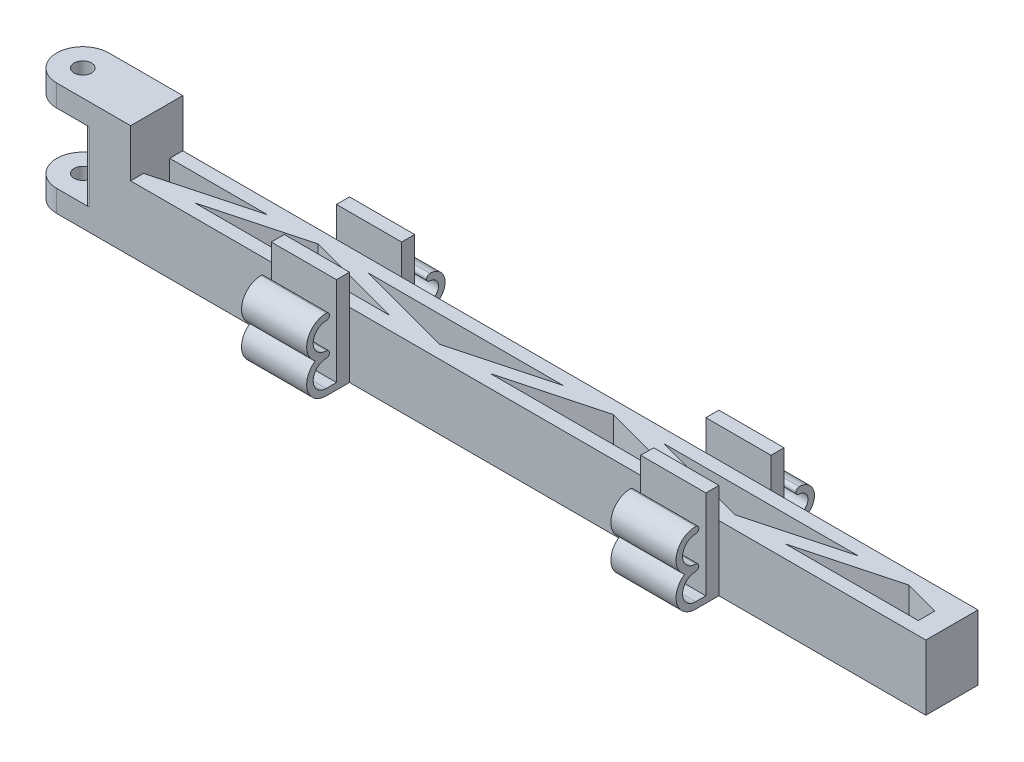
from build123d import *

# Parameters (mm, degrees)
SKETCH1_R            = 2
BOSS_EXTRUDE1_DEPTH  = 15
SKETCH2_R            = 2
BOSS_EXTRUDE2_DEPTH  = 5
SKETCH3_R            = 8
CUT_EXTRUDE1_DEPTH   = 15
BOSS_EXTRUDE3_DEPTH  = 15
SKETCH5_R            = 2
BOSS_EXTRUDE4_DEPTH  = 5
FILLET4_R            = 1
SKETCH11_W           = 15
SKETCH11_H           = 3
BOSS_EXTRUDE6_DEPTH  = 22
CUT_EXTRUDE4_DEPTH   = 8
BOSS_EXTRUDE7_DEPTH  = 1
SKETCH14_R           = 2
BOSS_EXTRUDE8_DEPTH  = 5
BOSS_EXTRUDE9_DEPTH  = 15
BOSS_EXTRUDE10_DEPTH = 15
BOSS_EXTRUDE11_DEPTH = 15
BOSS_EXTRUDE12_DEPTH = 15


with BuildPart() as part:
    # Sketch1 → Boss-Extrude1 (new body)
    with BuildSketch(Plane(origin=(0, 0, 0), x_dir=(1, 0, 0), z_dir=(0, 1, 0))):
        with BuildLine():
            Line((0, -6), (200, -6))
            Line((200, -6), (200, 6))
            Line((200, 6), (0, 6))
            ThreePointArc((0, 6), (-3, 5.196152423), (-5.196152423, 3))
            ThreePointArc((-5.196152423, 3), (-5.197498369, 2.997667544), (-5.198843268, 2.995334485))
            ThreePointArc((-5.198843268, 2.995334485), (-5.19480543, -3.002331851), (0, -6))
        make_face()
        Circle(SKETCH1_R, mode=Mode.SUBTRACT)
        with BuildLine():
            Line((39.568354484, 3), (17.176049639, -3))
            Line((17.176049639, -3), (5.999997583, -0.005385877))
            ThreePointArc((5.999997583, -0.005385877), (5.999999396, -0.002692939), (6, 0))
            ThreePointArc((6, 0), (5.795554958, 1.552914271), (5.196152423, 3))
            Line((5.196152423, 3), (39.568354484, 3))
        make_face(mode=Mode.SUBTRACT)
        Polygon((73.551769245, -3), (28.767159554, -3), (51.1594644, 3), align=None, mode=Mode.SUBTRACT)
        Polygon((85.142879161, -3), (62.750574315, 3), (107.535184006, 3), align=None, mode=Mode.SUBTRACT)
        Polygon((141.518598767, -3), (96.733989076, -3), (119.126293922, 3), align=None, mode=Mode.SUBTRACT)
        Polygon((153.109708683, -3), (130.717403837, 3), (175.502013528, 3), align=None, mode=Mode.SUBTRACT)
        Polygon((195.25744983, 0.812375338), (195.25744983, -3), (164.700818598, -3), (187.093123443, 3), align=None, mode=Mode.SUBTRACT)
    extrude(amount=BOSS_EXTRUDE1_DEPTH)

    # Sketch2 → Boss-Extrude2 (add)
    with BuildSketch(Plane(origin=(0, 15, 0), x_dir=(1, 0, 0), z_dir=(0, 1, 0))):
        with BuildLine():
            Line((0, 6), (17, 6))
            Line((17, 6), (17, -6))
            Line((17, -6), (0, -6))
            ThreePointArc((0, -6), (-6, 0), (0, 6))
        make_face()
        Circle(SKETCH2_R, mode=Mode.SUBTRACT)
    extrude(amount=BOSS_EXTRUDE2_DEPTH)

    # Sketch3 → Cut-Extrude1 (cut)
    with BuildSketch(Plane.XZ):
        Circle(SKETCH3_R)
    extrude(amount=-CUT_EXTRUDE1_DEPTH, mode=Mode.SUBTRACT)

    # Sketch4 → Boss-Extrude3 (add)
    with BuildSketch(Plane.XZ.offset(-15)):
        with BuildLine():
            Line((7.416198487, -3), (17, -3))
            Line((17, -3), (17, 2.952827641))
            Line((17, 2.952827641), (7.981992906, 0.536459923))
            ThreePointArc((7.981992906, 0.536459923), (7.899538704, -1.2638387), (7.416198487, -3))
        make_face()
    extrude(amount=BOSS_EXTRUDE3_DEPTH)

    # Sketch5 → Boss-Extrude4 (add)
    with BuildSketch(Plane.XZ):
        with BuildLine():
            Line((17, -6), (17, 6))
            Line((17, 6), (0, 6))
            ThreePointArc((0, 6), (-6, 0), (0, -6))
            Line((0, -6), (17, -6))
        make_face()
        Circle(SKETCH5_R, mode=Mode.SUBTRACT)
    extrude(amount=-BOSS_EXTRUDE4_DEPTH)

    # Fillet4
    fillet4_edges = [part.edges().sort_by_distance(p)[0] for p in [
        (5.291502622, 10, -6),
        (5.291502622, 10, 6),
    ]]
    fillet(fillet4_edges, radius=FILLET4_R)

    # Sketch11 → Boss-Extrude6 (add)
    with BuildSketch(Plane.XZ):
        with Locations((59.870503333, 7.5)):
            Rectangle(SKETCH11_W, SKETCH11_H)
        with Locations((59.870503333, -7.5)):
            Rectangle(SKETCH11_W, SKETCH11_H)
        with Locations((144.870503333, 7.5)):
            Rectangle(SKETCH11_W, SKETCH11_H)
        with Locations((144.870503333, -7.5)):
            Rectangle(SKETCH11_W, SKETCH11_H)
    extrude(amount=-BOSS_EXTRUDE6_DEPTH)

    # Sketch12 → Cut-Extrude4 (cut, through all)
    with BuildSketch(Plane.XZ.offset(-15)):
        with BuildLine():
            Line((0, -6), (7.483314774, -6))
            ThreePointArc((7.483314774, -6), (6.60139767, -5.471404521), (6.651835354, -4.444444444))
            ThreePointArc((6.651835354, -4.444444444), (8, 0), (6.651835354, 4.444444444))
            ThreePointArc((6.651835354, 4.444444444), (6.60139767, 5.471404521), (7.483314774, 6))
            Line((7.483314774, 6), (0, 6))
            ThreePointArc((0, 6), (-6, 0), (0, -6))
        make_face()
    extrude(amount=-CUT_EXTRUDE4_DEPTH, mode=Mode.SUBTRACT)

    # Sketch13 → Boss-Extrude7 (add)
    with BuildSketch(Plane(origin=(0, 20, 0), x_dir=(1, 0, 0), z_dir=(0, 1, 0))):
        with BuildLine():
            Line((7.483314774, -6), (17, -6))
            Line((17, -6), (17, 6))
            Line((17, 6), (7.483314774, 6))
            ThreePointArc((7.483314774, 6), (6.60139767, 5.471404521), (6.651835354, 4.444444444))
            ThreePointArc((6.651835354, 4.444444444), (8, 0), (6.651835354, -4.444444444))
            ThreePointArc((6.651835354, -4.444444444), (6.60139767, -5.471404521), (7.483314774, -6))
        make_face()
    extrude(amount=BOSS_EXTRUDE7_DEPTH)

    # Sketch14 → Boss-Extrude8 (add)
    with BuildSketch(Plane(origin=(0, 21, 0), x_dir=(1, 0, 0), z_dir=(0, 1, 0))):
        with BuildLine():
            Line((0, -6), (7.483314774, -6))
            Line((7.483314774, -6), (17, -6))
            Line((17, -6), (17, 6))
            Line((17, 6), (7.483314774, 6))
            Line((7.483314774, 6), (0, 6))
            ThreePointArc((0, 6), (-6, 0), (0, -6))
        make_face()
        Circle(SKETCH14_R, mode=Mode.SUBTRACT)
    extrude(amount=BOSS_EXTRUDE8_DEPTH)

    # Sketch17 → Boss-Extrude9 (add)
    with BuildSketch(Plane.ZY.offset(-52.370503333)):
        with BuildLine():
            Line((-12.5, 1.5), (-9, 1.5))
            Line((-9, 1.5), (-9, 0))
            Line((-9, 0), (-12.5, 0))
            ThreePointArc((-12.5, 0), (-15.807189139, 2.354356076), (-14.665063509, 6.25))
            ThreePointArc((-14.665063509, 6.25), (-15.807189139, 10.145643924), (-12.5, 12.5))
            ThreePointArc((-12.5, 12.5), (-11.75, 11.75), (-12.5, 11))
            ThreePointArc((-12.5, 11), (-14.5, 9), (-12.5, 7))
            ThreePointArc((-12.5, 7), (-11.75, 6.25), (-12.5, 5.5))
            ThreePointArc((-12.5, 5.5), (-14.5, 3.5), (-12.5, 1.5))
        make_face()
    extrude(amount=-BOSS_EXTRUDE9_DEPTH)

    # Sketch18 → Boss-Extrude10 (add)
    with BuildSketch(Plane(origin=(152.370503333, 0, 0), x_dir=(0, 0, -1), z_dir=(1, 0, 0))):
        with BuildLine():
            Line((6, 0), (12.5, 0))
            ThreePointArc((12.5, 0), (15.807189139, 2.354356076), (14.665063509, 6.25))
            ThreePointArc((14.665063509, 6.25), (15.807189139, 10.145643924), (12.5, 12.5))
            ThreePointArc((12.5, 12.5), (11.75, 11.75), (12.5, 11))
            ThreePointArc((12.5, 11), (14.5, 9), (12.5, 7))
            ThreePointArc((12.5, 7), (11.75, 6.25), (12.5, 5.5))
            ThreePointArc((12.5, 5.5), (14.5, 3.5), (12.5, 1.5))
            Line((12.5, 1.5), (9, 1.5))
            Line((9, 1.5), (9, 22))
            Line((9, 22), (6, 22))
            Line((6, 22), (6, 15))
            Line((6, 15), (6, 0))
        make_face()
    extrude(amount=-BOSS_EXTRUDE10_DEPTH)

    # Sketch20 → Boss-Extrude11 (add)
    with BuildSketch(Plane(origin=(152.370503333, 0, 0), x_dir=(0, 0, -1), z_dir=(1, 0, 0))):
        with BuildLine():
            Line((-11.364782306, 0), (-9, 0))
            Line((-9, 0), (-9, 1.5))
            Line((-9, 1.5), (-11.364782306, 1.5))
            add(Edge.make_bspline(
                [(-11.364782306, 7.5), (-14.358451493, 7.5), (-14.358451493, 4.5), (-14.358451493, 1.5), (-11.364782306, 1.5)],
                knots=[0, 0, 0, 1.570796327, 1.570796327, 3.141592654, 3.141592654, 3.141592654], degree=2, weights=[1, 0.707106781, 1, 0.707106781, 1]))
            add(Edge.make_bspline(
                [(-11.364782306, 7.5), (-10.616365009, 7.5), (-10.616365009, 8.25), (-10.616365009, 9), (-11.364782306, 9)],
                knots=[3.141592654, 3.141592654, 3.141592654, 4.71238898, 4.71238898, 6.283185307, 6.283185307, 6.283185307], degree=2, weights=[1, 0.707106781, 1, 0.707106781, 1]))
            add(Edge.make_bspline(
                [(-11.364782306, 15), (-14.358451493, 15), (-14.358451493, 12), (-14.358451493, 9), (-11.364782306, 9)],
                knots=[0, 0, 0, 1.570796327, 1.570796327, 3.141592654, 3.141592654, 3.141592654], degree=2, weights=[1, 0.707106781, 1, 0.707106781, 1]))
            add(Edge.make_bspline(
                [(-11.364782306, 15), (-10.616365009, 15), (-10.616365009, 15.75), (-10.616365009, 16.5), (-11.364782306, 16.5)],
                knots=[3.141592654, 3.141592654, 3.141592654, 4.71238898, 4.71238898, 6.283185307, 6.283185307, 6.283185307], degree=2, weights=[1, 0.707106781, 1, 0.707106781, 1]))
            add(Edge.make_bspline(
                [(-11.364782306, 16.5), (-26.258098465, 16.5), (-13.847001666, 8.25)],
                knots=[0, 0, 0, 2.55590711, 2.55590711, 2.55590711], degree=2, weights=[1, 0.288675135, 1]))
            add(Edge.make_bspline(
                [(-13.847001666, 8.25), (-26.258098465, 0), (-11.364782306, 0)],
                knots=[0.585685543, 0.585685543, 0.585685543, 3.141592654, 3.141592654, 3.141592654], degree=2, weights=[1, 0.288675135, 1]))
        make_face()
    extrude(amount=-BOSS_EXTRUDE11_DEPTH)

    # Sketch21 → Boss-Extrude12 (add)
    with BuildSketch(Plane.ZY.offset(-52.370503333)):
        with BuildLine():
            Line((6, 0), (11.364782306, 0))
            add(Edge.make_bspline(
                [(11.364782306, 0), (26.258098465, 0), (13.847001666, 8.25)],
                knots=[3.141592654, 3.141592654, 3.141592654, 5.697499764, 5.697499764, 5.697499764], degree=2, weights=[1, 0.288675135, 1]))
            add(Edge.make_bspline(
                [(13.847001666, 8.25), (26.258098465, 16.5), (11.364782306, 16.5)],
                knots=[3.727278197, 3.727278197, 3.727278197, 6.283185307, 6.283185307, 6.283185307], degree=2, weights=[1, 0.288675135, 1]))
            add(Edge.make_bspline(
                [(11.364782306, 16.5), (10.616365009, 16.5), (10.616365009, 15.75), (10.616365009, 15), (11.364782306, 15)],
                knots=[0, 0, 0, 1.570796327, 1.570796327, 3.141592654, 3.141592654, 3.141592654], degree=2, weights=[1, 0.707106781, 1, 0.707106781, 1]))
            add(Edge.make_bspline(
                [(11.364782306, 9), (14.358451493, 9), (14.358451493, 12), (14.358451493, 15), (11.364782306, 15)],
                knots=[3.141592654, 3.141592654, 3.141592654, 4.71238898, 4.71238898, 6.283185307, 6.283185307, 6.283185307], degree=2, weights=[1, 0.707106781, 1, 0.707106781, 1]))
            add(Edge.make_bspline(
                [(11.364782306, 9), (10.616365009, 9), (10.616365009, 8.25), (10.616365009, 7.5), (11.364782306, 7.5)],
                knots=[0, 0, 0, 1.570796327, 1.570796327, 3.141592654, 3.141592654, 3.141592654], degree=2, weights=[1, 0.707106781, 1, 0.707106781, 1]))
            add(Edge.make_bspline(
                [(11.364782306, 1.5), (14.358451493, 1.5), (14.358451493, 4.5), (14.358451493, 7.5), (11.364782306, 7.5)],
                knots=[3.141592654, 3.141592654, 3.141592654, 4.71238898, 4.71238898, 6.283185307, 6.283185307, 6.283185307], degree=2, weights=[1, 0.707106781, 1, 0.707106781, 1]))
            Line((11.364782306, 1.5), (9, 1.5))
            Line((9, 1.5), (9, 22))
            Line((9, 22), (6, 22))
            Line((6, 22), (6, 15))
            Line((6, 15), (6, 0))
        make_face()
    extrude(amount=-BOSS_EXTRUDE12_DEPTH)


solid = part.part
